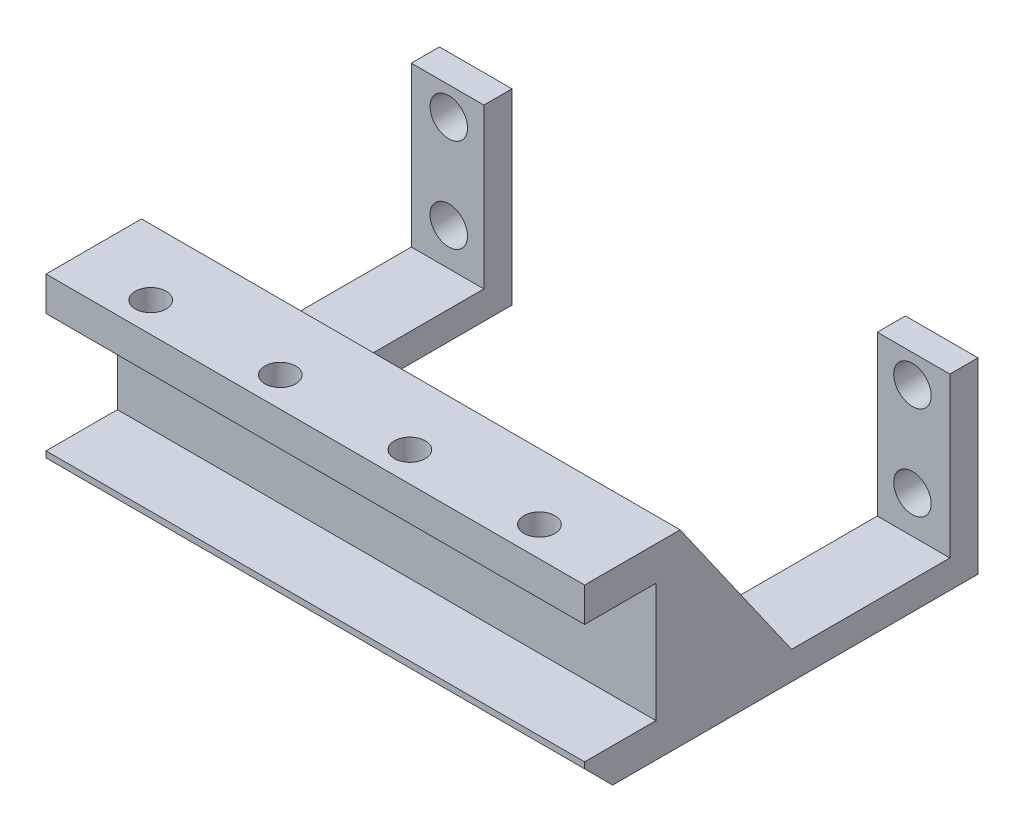
from build123d import *

# Parameters (mm, degrees)
SKETCH1_W                 = 57.5
SKETCH1_H                 = 42
BOSS_EXTRUDE1_DEPTH       = 20
CUT_EXTRUDE1_DEPTH        = 21
CUT_EXTRUDE2_DEPTH        = 58.5
CUT_EXTRUDE3_REACH        = 44
SKETCH4_R                 = 2
SKETCH5_W                 = 7.62
SKETCH5_H                 = 12.7
CUT_EXTRUDE4_DEPTH        = 58.5
M4X0_7_TAPPED_HOLE1_D     = 3.3
M4X0_7_TAPPED_HOLE1_DEPTH = 3.65
CHAMFER1_SIZE             = 3


with BuildPart() as part:
    # Sketch1 → Boss-Extrude1 (new body)
    with BuildSketch(Plane(origin=(0, 0, 0), x_dir=(1, 0, 0), z_dir=(0, 1, 0))):
        with Locations((28.75, 21)):
            Rectangle(SKETCH1_W, SKETCH1_H)
    extrude(amount=BOSS_EXTRUDE1_DEPTH)

    # Sketch2 → Cut-Extrude1 (cut, through all)
    with BuildSketch(Plane(origin=(0, 20, 0), x_dir=(1, 0, 0), z_dir=(0, 1, 0))):
        with BuildLine():
            Line((7.75, 42), (7.75, 15.2))
            ThreePointArc((7.75, 15.2), (9.214466094, 11.664466094), (12.75, 10.2))
            Line((12.75, 10.2), (44.75, 10.2))
            ThreePointArc((44.75, 10.2), (48.285533906, 11.664466094), (49.75, 15.2))
            Line((49.75, 15.2), (49.75, 42))
            Line((49.75, 42), (7.75, 42))
        make_face()
    extrude(amount=-CUT_EXTRUDE1_DEPTH, mode=Mode.SUBTRACT)

    # Sketch3 → Cut-Extrude2 (cut, through all)
    with BuildSketch(Plane(origin=(57.5, 0, 0), x_dir=(0, 0, -1), z_dir=(1, 0, 0))):
        Polygon((39, 20), (39, 3), (22.10352815, 3), (10.2, 20), align=None)
    extrude(amount=-CUT_EXTRUDE2_DEPTH, mode=Mode.SUBTRACT)

    # Sketch4 → Cut-Extrude3 (cut, up to next)
    with BuildSketch(Plane(origin=(0, 0, -42), x_dir=(-1, 0, 0), z_dir=(0, 0, -1)), mode=Mode.PRIVATE) as cut_extrude3_sk1:
        with Locations((-53.5, 17)):
            Circle(SKETCH4_R)
    cut_extrude3_tool1 = extrude(cut_extrude3_sk1.sketch, amount=-CUT_EXTRUDE3_REACH, mode=Mode.PRIVATE) & part.part
    add(cut_extrude3_tool1.solids().sort_by_distance((53.5, 17, -42))[0], mode=Mode.SUBTRACT)
    # Sketch4 → Cut-Extrude3 (cut, up to next)
    with BuildSketch(Plane(origin=(0, 0, -42), x_dir=(-1, 0, 0), z_dir=(0, 0, -1)), mode=Mode.PRIVATE) as cut_extrude3_sk2:
        with Locations((-4, 17)):
            Circle(SKETCH4_R)
    cut_extrude3_tool2 = extrude(cut_extrude3_sk2.sketch, amount=-CUT_EXTRUDE3_REACH, mode=Mode.PRIVATE) & part.part
    add(cut_extrude3_tool2.solids().sort_by_distance((4, 17, -42))[0], mode=Mode.SUBTRACT)
    # Sketch4 → Cut-Extrude3 (cut, up to next)
    with BuildSketch(Plane(origin=(0, 0, -42), x_dir=(-1, 0, 0), z_dir=(0, 0, -1)), mode=Mode.PRIVATE) as cut_extrude3_sk3:
        with Locations((-4, 7)):
            Circle(SKETCH4_R)
    cut_extrude3_tool3 = extrude(cut_extrude3_sk3.sketch, amount=-CUT_EXTRUDE3_REACH, mode=Mode.PRIVATE) & part.part
    add(cut_extrude3_tool3.solids().sort_by_distance((4, 7, -42))[0], mode=Mode.SUBTRACT)
    # Sketch4 → Cut-Extrude3 (cut, up to next)
    with BuildSketch(Plane(origin=(0, 0, -42), x_dir=(-1, 0, 0), z_dir=(0, 0, -1)), mode=Mode.PRIVATE) as cut_extrude3_sk4:
        with Locations((-53.5, 7)):
            Circle(SKETCH4_R)
    cut_extrude3_tool4 = extrude(cut_extrude3_sk4.sketch, amount=-CUT_EXTRUDE3_REACH, mode=Mode.PRIVATE) & part.part
    add(cut_extrude3_tool4.solids().sort_by_distance((53.5, 7, -42))[0], mode=Mode.SUBTRACT)

    # Sketch5 → Cut-Extrude4 (cut, through all)
    with BuildSketch(Plane(origin=(57.5, 0, 0), x_dir=(0, 0, -1), z_dir=(1, 0, 0))):
        with Locations((3.81, 10)):
            Rectangle(SKETCH5_W, SKETCH5_H)
    extrude(amount=-CUT_EXTRUDE4_DEPTH, mode=Mode.SUBTRACT)

    # M4x0.7 Tapped Hole1
    with Locations(Plane(origin=(0, 20, 0), x_dir=(1, 0, 0), z_dir=(0, 1, 0))):
        with Locations((8, 3.18), (21.833333333, 3.18), (35.666666667, 3.18), (49.5, 3.18)):
            Hole(M4X0_7_TAPPED_HOLE1_D / 2, depth=M4X0_7_TAPPED_HOLE1_DEPTH)

    # Chamfer1
    chamfer1_edges = [part.edges().sort_by_distance(p)[0] for p in [
        (28.75, 0, 0),
    ]]
    chamfer(chamfer1_edges, length=CHAMFER1_SIZE)


solid = part.part
